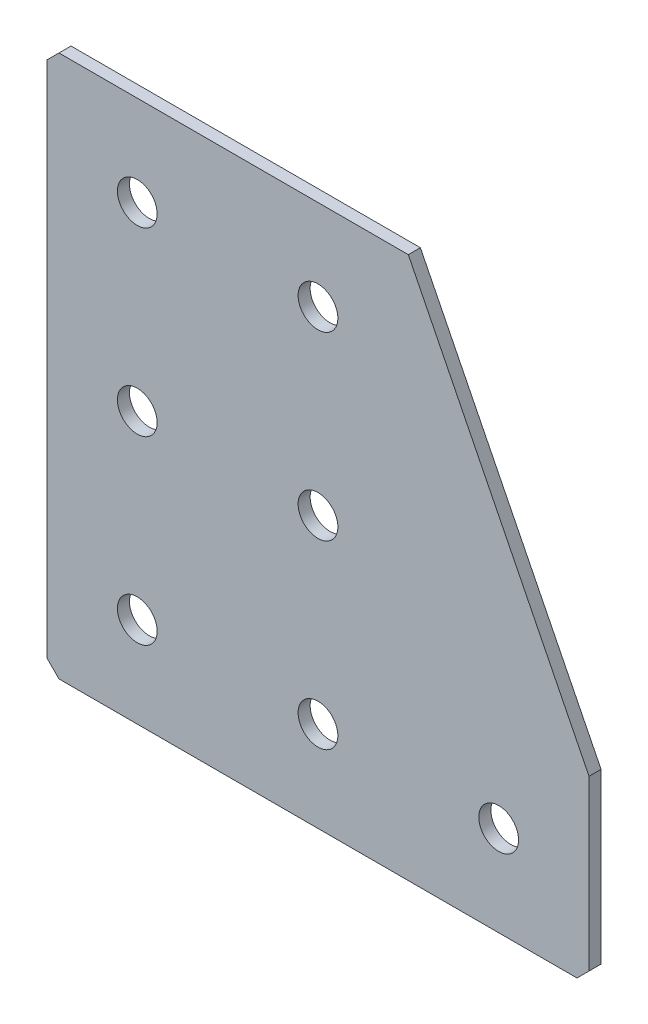
from build123d import *

# Parameters (mm, degrees)
EXTRUDE_1_DEPTH   = 2
HOLE_WIZARD_M61_D = 6.6
CHAMFER_1_SIZE    = 2


with BuildPart() as part:
    # Эскиз1 → Бобышка-Вытянуть1 (new body)
    with BuildSketch(Plane(origin=(0, 0, 0), x_dir=(1, 0, 0), z_dir=(0, 0, -1))):
        Polygon((0, 0), (0, 90), (90, 90), (90, 60), (60, 0), align=None)
    extrude(amount=EXTRUDE_1_DEPTH)

    # Отверстие с зазором M61 (through all)
    with Locations(Plane(origin=(0, 0, -2), x_dir=(1, 0, 0), z_dir=(0, 0, -1))):
        with Locations((45, 75), (15, 75), (15, 45), (15, 15), (75, 75), (45, 45), (45, 15)):
            Hole(HOLE_WIZARD_M61_D / 2)

    # Фаска1
    chamfer_1_edges = [part.edges().sort_by_distance(p)[0] for p in [
        (0, 0, -1),
        (0, -90, -1),
        (90, -90, -1),
    ]]
    chamfer(chamfer_1_edges, length=CHAMFER_1_SIZE)


solid = part.part
